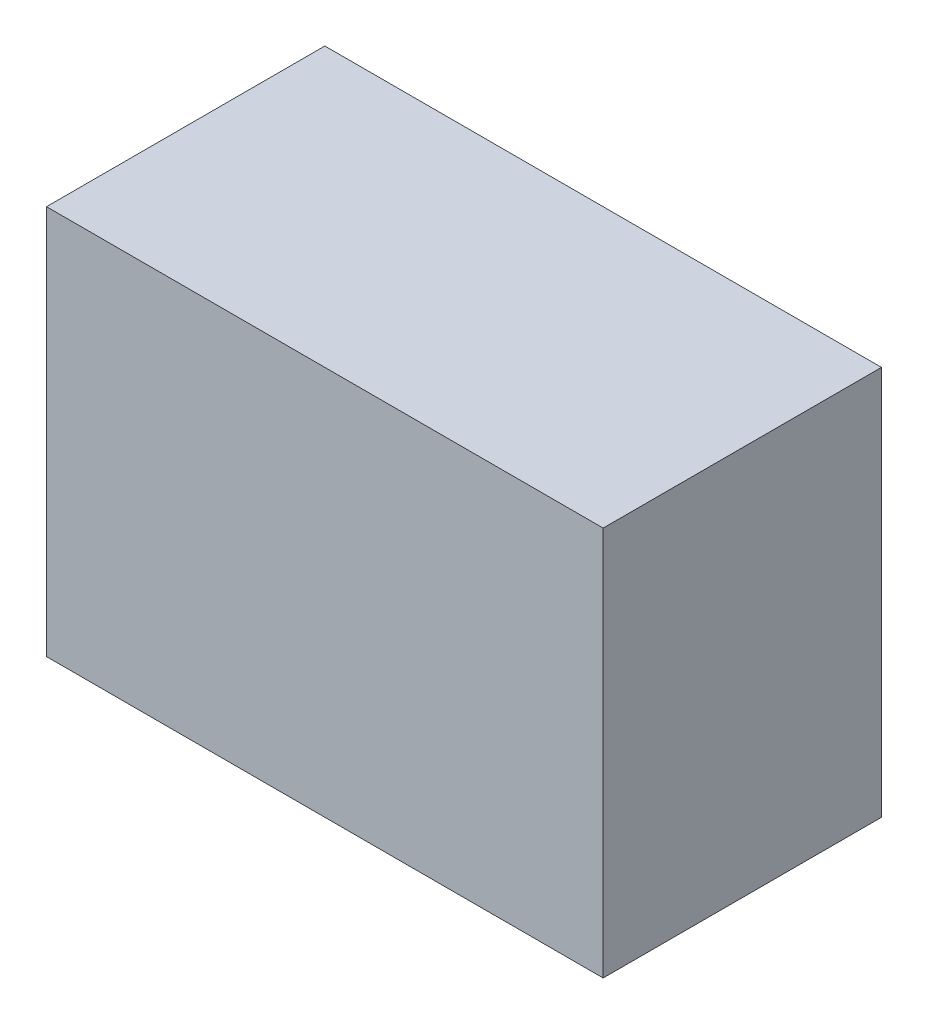
from build123d import *

# Parameters (mm, degrees)
SKETCH_2_W      = 1000
SKETCH_2_H      = 700
EXTRUDE_1_DEPTH = 500
SHELL_1_T       = -3


with BuildPart() as part:
    # 草图2 → 拉伸1 (new body)
    with BuildSketch(Plane.XY):
        Rectangle(SKETCH_2_W, SKETCH_2_H)
    extrude(amount=EXTRUDE_1_DEPTH)

    # 抽壳1
    shell_1_openings = [part.faces().sort_by_distance(p)[0] for p in [
        (0, 0, 0),
    ]]
    offset(amount=SHELL_1_T, openings=shell_1_openings, kind=Kind.INTERSECTION)


solid = part.part
